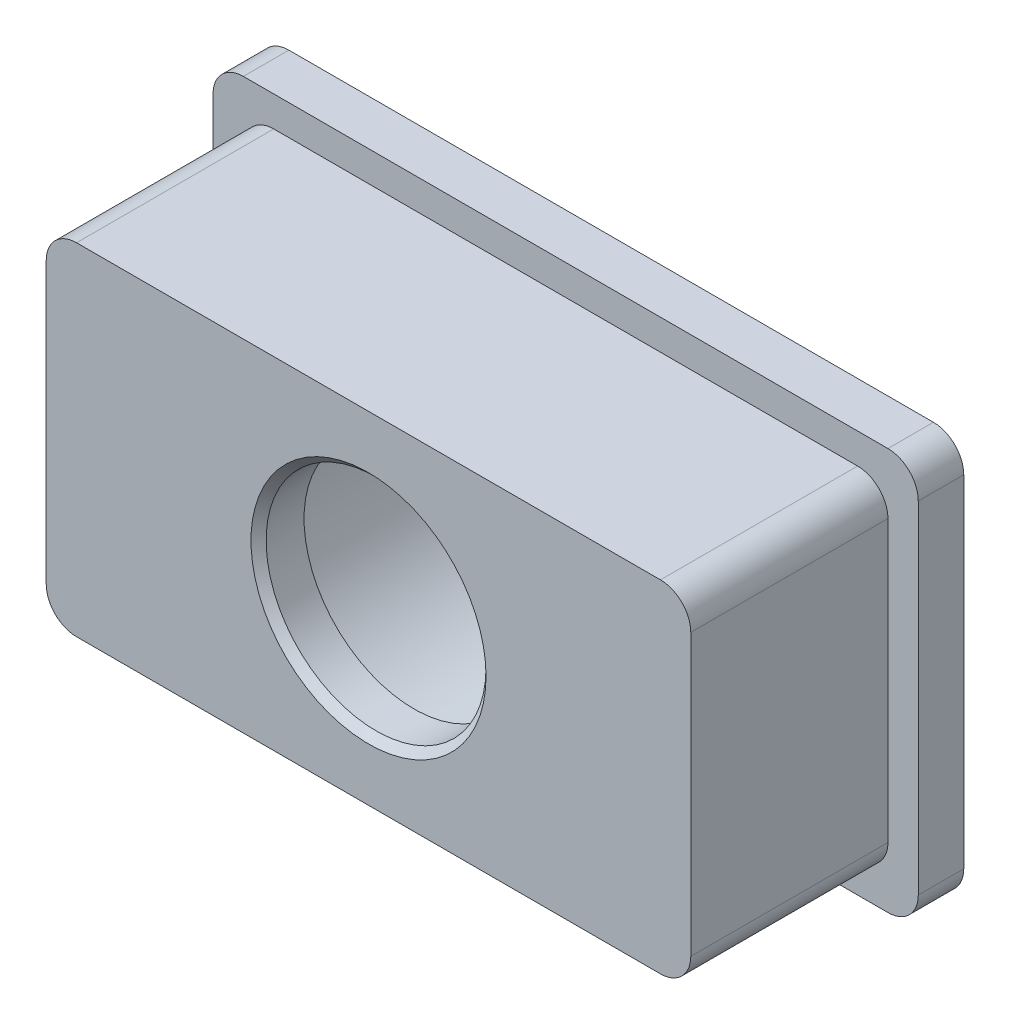
from build123d import *

# Parameters (mm, degrees)
SKETCH1_W           = 42.5
SKETCH1_H           = 22.5
BOSS_EXTRUDE1_DEPTH = 13
SKETCH2_W           = 46.5
SKETCH2_H           = 26.5
BOSS_EXTRUDE2_DEPTH = 3
CUT_EXTRUDE2_REACH  = 18
SKETCH6_R           = 10.25
SKETCH7_R           = 10.25
SKETCH7_R_2         = 7.25
BOSS_EXTRUDE4_DEPTH = 3
FILLET1_R           = 2
CHAMFER1_SIZE       = 0.5


with BuildPart() as part:
    # Sketch1 → Boss-Extrude1 (new body)
    with BuildSketch(Plane.XY):
        Rectangle(SKETCH1_W, SKETCH1_H)
    extrude(amount=BOSS_EXTRUDE1_DEPTH)

    # Sketch2 → Boss-Extrude2 (add)
    with BuildSketch(Plane(origin=(0, 0, 0), x_dir=(-1, 0, 0), z_dir=(0, 0, -1))):
        Rectangle(SKETCH2_W, SKETCH2_H)
    extrude(amount=BOSS_EXTRUDE2_DEPTH)

    # Sketch6 → Cut-Extrude2 (cut, up to next)
    with BuildSketch(Plane(origin=(0, 0, -3), x_dir=(-1, 0, 0), z_dir=(0, 0, -1)), mode=Mode.PRIVATE) as cut_extrude2_sk1:
        Circle(SKETCH6_R)
    cut_extrude2_tool1 = extrude(cut_extrude2_sk1.sketch, amount=-CUT_EXTRUDE2_REACH, mode=Mode.PRIVATE) & part.part
    add(cut_extrude2_tool1.solids().sort_by_distance((0, 0, -3))[0], mode=Mode.SUBTRACT)

    # Sketch7 → Boss-Extrude4 (add)
    with BuildSketch(Plane.XY.offset(13)):
        Circle(SKETCH7_R)
        Circle(SKETCH7_R_2, mode=Mode.SUBTRACT)
    extrude(amount=-BOSS_EXTRUDE4_DEPTH)

    # Fillet1
    fillet1_edges = [part.edges().sort_by_distance(p)[0] for p in [
        (-23.25, -13.25, -1.5),
        (-23.25, 13.25, -1.5),
        (23.25, 13.25, -1.5),
        (23.25, -13.25, -1.5),
        (21.25, -11.25, 6.5),
        (-21.25, -11.25, 6.5),
        (-21.25, 11.25, 6.5),
        (21.25, 11.25, 6.5),
    ]]
    fillet(fillet1_edges, radius=FILLET1_R)

    # Chamfer1
    chamfer1_edges = [part.edges().sort_by_distance(p)[0] for p in [
        (10.25, 0, -3),
        (-7.25, 0, 13),
    ]]
    chamfer(chamfer1_edges, length=CHAMFER1_SIZE)


solid = part.part
